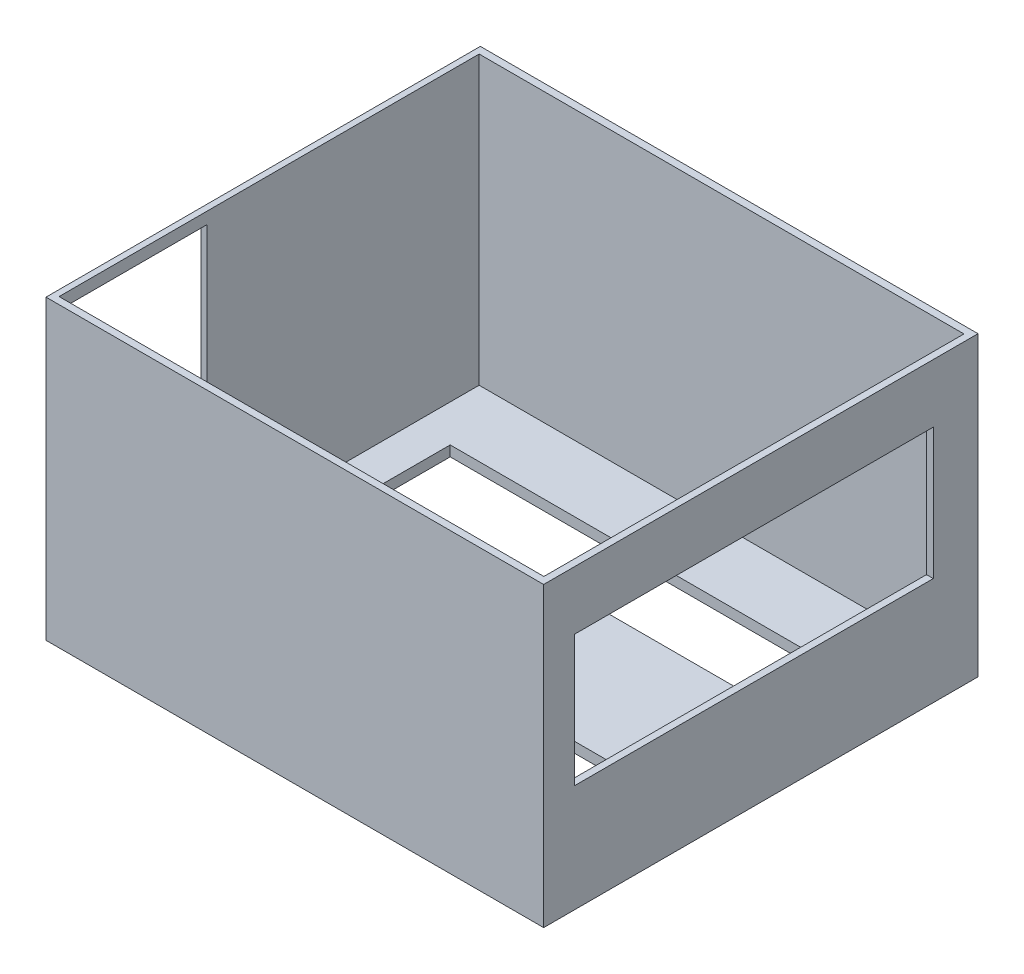
from build123d import *

# Parameters (mm, degrees)
SKETCH1_W           = 144
SKETCH1_H           = 125.68
BOSS_EXTRUDE1_DEPTH = 3
SKETCH2_W           = 144
SKETCH2_H           = 125.68
SKETCH2_W_2         = 140.282516161
SKETCH2_H_2         = 121.548177757
BOSS_EXTRUDE2_DEPTH = 83
SKETCH4_W           = 103.746737409
SKETCH4_H           = 37.953937335
CUT_EXTRUDE1_DEPTH  = 20
SKETCH5_W           = 110.713821745
SKETCH5_H           = 19.414835186
SKETCH5_H_2         = 24.021424071
CUT_EXTRUDE2_DEPTH  = 20
SKETCH6_W           = 39.790164022
SKETCH6_H           = 75.651590962
CUT_EXTRUDE3_DEPTH  = 20


with BuildPart() as part:
    # Sketch1 → Boss-Extrude1 (new body)
    with BuildSketch(Plane(origin=(0, 0, 0), x_dir=(1, 0, 0), z_dir=(0, 1, 0))):
        with Locations((-0.900426333, 18.508659662)):
            Rectangle(SKETCH1_W, SKETCH1_H)
    extrude(amount=BOSS_EXTRUDE1_DEPTH)

    # Sketch2 → Boss-Extrude2 (add)
    with BuildSketch(Plane(origin=(0, 3, 0), x_dir=(1, 0, 0), z_dir=(0, 1, 0))):
        with Locations((-0.900426333, 18.508659662)):
            Rectangle(SKETCH2_W, SKETCH2_H)
        with Locations((-1.012042147, 18.478566742)):
            Rectangle(SKETCH2_W_2, SKETCH2_H_2, mode=Mode.SUBTRACT)
    extrude(amount=BOSS_EXTRUDE2_DEPTH)

    # Sketch4 → Cut-Extrude1 (cut)
    with BuildSketch(Plane(origin=(71.099573667, 0, 0), x_dir=(0, 0, -1), z_dir=(1, 0, 0))):
        with Locations((16.534795252, 50.079604952)):
            Rectangle(SKETCH4_W, SKETCH4_H)
    extrude(amount=-CUT_EXTRUDE1_DEPTH, mode=Mode.SUBTRACT)

    # Sketch5 → Cut-Extrude2 (cut)
    with BuildSketch(Plane.XZ):
        with Locations((-5.028686967, -50.405830616)):
            Rectangle(SKETCH5_W, SKETCH5_H)
        with Locations((-5.028686967, 8.182044553)):
            Rectangle(SKETCH5_W, SKETCH5_H_2)
    extrude(amount=-CUT_EXTRUDE2_DEPTH, mode=Mode.SUBTRACT)

    # Sketch6 → Cut-Extrude3 (cut)
    with BuildSketch(Plane.ZY.offset(72.900426333)):
        with Locations((19.353212204, 44.793227562)):
            Rectangle(SKETCH6_W, SKETCH6_H)
    extrude(amount=-CUT_EXTRUDE3_DEPTH, mode=Mode.SUBTRACT)


solid = part.part
